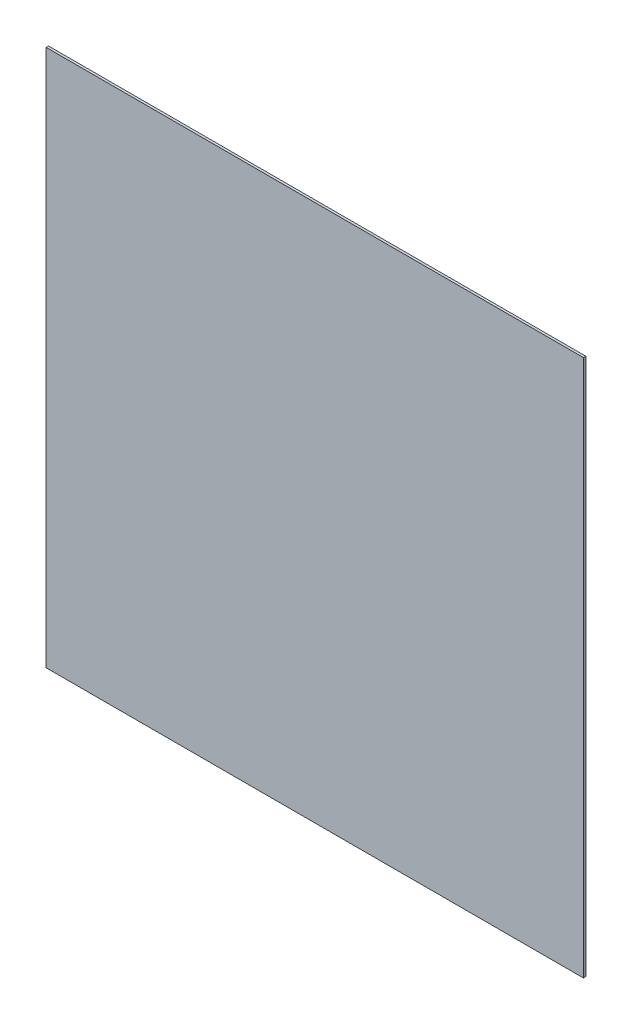
from build123d import *

# Parameters (mm, degrees)
ESQUISSE1_W        = 1066.8
ESQUISSE1_H        = 1066.8
BOSS_EXTRU_1_DEPTH = 4.7625


with BuildPart() as part:
    # Esquisse1 → Boss.-Extru.1 (new body)
    with BuildSketch(Plane.XY):
        with Locations((533.4, -533.4)):
            Rectangle(ESQUISSE1_W, ESQUISSE1_H)
    extrude(amount=BOSS_EXTRU_1_DEPTH)


solid = part.part
